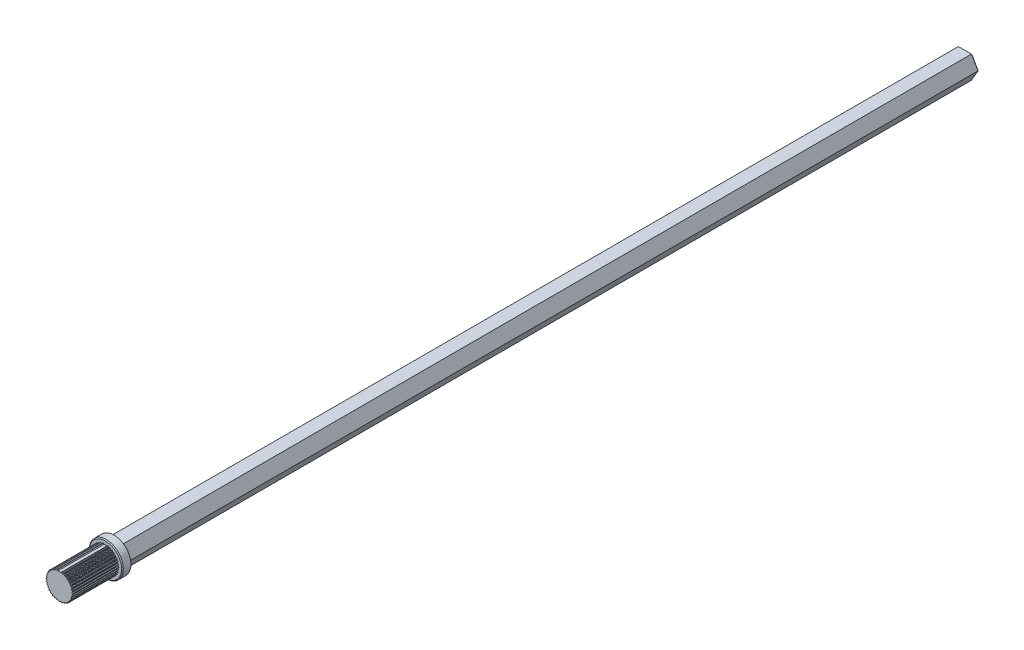
from build123d import *

# Parameters (mm, degrees)
BOSS_EXTRUDE1_DEPTH = 500
SKETCH2_R           = 10
BOSS_EXTRUDE2_DEPTH = 5
BOSS_EXTRUDE3_DEPTH = 27
PAH1_SIZE           = 0.5


with BuildPart() as part:
    # Sketch1 → Boss-Extrude1 (new body)
    with BuildSketch(Plane.XY):
        Polygon((7.696079088, 0), (3.848039544, 6.665), (-3.848039544, 6.665), (-7.696079088, 0), (-3.848039544, -6.665), (3.848039544, -6.665), align=None)
    extrude(amount=BOSS_EXTRUDE1_DEPTH)

    # Sketch2 → Boss-Extrude2 (add)
    with BuildSketch(Plane.XY.offset(500)):
        Circle(SKETCH2_R)
    extrude(amount=BOSS_EXTRUDE2_DEPTH)

    # Sketch3 → Boss-Extrude3 (add)
    with BuildSketch(Plane.XY.offset(505)):
        with BuildLine():
            Line((5.932852577, 5.108414624), (5.40374633, 5.108414624))
            ThreePointArc((5.40374633, 5.108414624), (5.258154352, 5.258154352), (5.108414624, 5.40374633))
            Line((5.108414624, 5.40374633), (5.108414624, 5.932852577))
            ThreePointArc((5.108414624, 5.932852577), (5.061919783, 6.032561087), (4.955652325, 6.061035366))
            Line((4.955652325, 6.061035366), (4.434584391, 5.96915703))
            ThreePointArc((4.434584391, 5.96915703), (4.265202251, 6.091340093), (4.092455625, 6.208718171))
            Line((4.092455625, 6.208718171), (4.000577289, 6.729786106))
            ThreePointArc((4.000577289, 6.729786106), (3.937474608, 6.819906075), (3.827877085, 6.829494615))
            Line((3.827877085, 6.829494615), (3.330679849, 6.648529621))
            ThreePointArc((3.330679849, 6.648529621), (3.142654138, 6.739443548), (2.952149432, 6.825041253))
            Line((2.952149432, 6.825041253), (2.771184438, 7.322238489))
            ThreePointArc((2.771184438, 7.322238489), (2.69339126, 7.400031667), (2.583793737, 7.390443126))
            Line((2.583793737, 7.390443126), (2.125574285, 7.125890003))
            ThreePointArc((2.125574285, 7.125890003), (1.92461807, 7.182772421), (1.722143673, 7.23398891))
            Line((1.722143673, 7.23398891), (1.457590549, 7.692208361))
            ThreePointArc((1.457590549, 7.692208361), (1.367470581, 7.755311042), (1.261203123, 7.726836763))
            Line((1.261203123, 7.726836763), (0.855884222, 7.386733823))
            Line((0.855884222, 7.386733823), (-0.855884222, 7.386733823))
            Line((-0.855884222, 7.386733823), (-1.261203123, 7.726836763))
            ThreePointArc((-1.261203123, 7.726836763), (-1.367470581, 7.755311042), (-1.457590549, 7.692208361))
            Line((-1.457590549, 7.692208361), (-1.722143673, 7.23398891))
            ThreePointArc((-1.722143673, 7.23398891), (-1.92461807, 7.182772421), (-2.125574285, 7.125890003))
            Line((-2.125574285, 7.125890003), (-2.583793737, 7.390443126))
            ThreePointArc((-2.583793737, 7.390443126), (-2.69339126, 7.400031667), (-2.771184438, 7.322238489))
            Line((-2.771184438, 7.322238489), (-2.952149432, 6.825041253))
            ThreePointArc((-2.952149432, 6.825041253), (-3.142654138, 6.739443548), (-3.330679849, 6.648529621))
            Line((-3.330679849, 6.648529621), (-3.827877085, 6.829494615))
            ThreePointArc((-3.827877085, 6.829494615), (-3.937474608, 6.819906075), (-4.000577289, 6.729786106))
            Line((-4.000577289, 6.729786106), (-4.092455625, 6.208718171))
            ThreePointArc((-4.092455625, 6.208718171), (-4.265202251, 6.091340093), (-4.434584391, 5.96915703))
            Line((-4.434584391, 5.96915703), (-4.955652325, 6.061035366))
            ThreePointArc((-4.955652325, 6.061035366), (-5.061919783, 6.032561087), (-5.108414624, 5.932852577))
            Line((-5.108414624, 5.932852577), (-5.108414624, 5.40374633))
            ThreePointArc((-5.108414624, 5.40374633), (-5.258154352, 5.258154352), (-5.40374633, 5.108414624))
            Line((-5.40374633, 5.108414624), (-5.932852577, 5.108414624))
            ThreePointArc((-5.932852577, 5.108414624), (-6.032561087, 5.061919783), (-6.061035366, 4.955652325))
            Line((-6.061035366, 4.955652325), (-5.96915703, 4.434584391))
            ThreePointArc((-5.96915703, 4.434584391), (-6.091340093, 4.265202251), (-6.208718171, 4.092455625))
            Line((-6.208718171, 4.092455625), (-6.729786106, 4.000577289))
            ThreePointArc((-6.729786106, 4.000577289), (-6.819906075, 3.937474608), (-6.829494615, 3.827877085))
            Line((-6.829494615, 3.827877085), (-6.648529621, 3.330679849))
            ThreePointArc((-6.648529621, 3.330679849), (-6.739443548, 3.142654138), (-6.825041253, 2.952149432))
            Line((-6.825041253, 2.952149432), (-7.322238489, 2.771184438))
            ThreePointArc((-7.322238489, 2.771184438), (-7.400031667, 2.69339126), (-7.390443126, 2.583793737))
            Line((-7.390443126, 2.583793737), (-7.125890003, 2.125574285))
            ThreePointArc((-7.125890003, 2.125574285), (-7.182772421, 1.92461807), (-7.23398891, 1.722143673))
            Line((-7.23398891, 1.722143673), (-7.692208361, 1.457590549))
            ThreePointArc((-7.692208361, 1.457590549), (-7.755311042, 1.367470581), (-7.726836763, 1.261203123))
            Line((-7.726836763, 1.261203123), (-7.386733823, 0.855884222))
            ThreePointArc((-7.386733823, 0.855884222), (-7.407856389, 0.648103455), (-7.423135474, 0.439811449))
            Line((-7.423135474, 0.439811449), (-7.828454374, 0.099708509))
            ThreePointArc((-7.828454374, 0.099708509), (-7.874949216, 0), (-7.828454374, -0.099708509))
            Line((-7.828454374, -0.099708509), (-7.423135474, -0.439811449))
            ThreePointArc((-7.423135474, -0.439811449), (-7.407856389, -0.648103455), (-7.386733823, -0.855884222))
            Line((-7.386733823, -0.855884222), (-7.726836763, -1.261203123))
            ThreePointArc((-7.726836763, -1.261203123), (-7.755311042, -1.367470581), (-7.692208361, -1.457590549))
            Line((-7.692208361, -1.457590549), (-7.23398891, -1.722143673))
            ThreePointArc((-7.23398891, -1.722143673), (-7.182772421, -1.92461807), (-7.125890003, -2.125574285))
            Line((-7.125890003, -2.125574285), (-7.390443126, -2.583793737))
            ThreePointArc((-7.390443126, -2.583793737), (-7.400031667, -2.69339126), (-7.322238489, -2.771184438))
            Line((-7.322238489, -2.771184438), (-6.825041253, -2.952149432))
            ThreePointArc((-6.825041253, -2.952149432), (-6.739443548, -3.142654138), (-6.648529621, -3.330679849))
            Line((-6.648529621, -3.330679849), (-6.829494615, -3.827877085))
            ThreePointArc((-6.829494615, -3.827877085), (-6.819906075, -3.937474608), (-6.729786106, -4.000577289))
            Line((-6.729786106, -4.000577289), (-6.208718171, -4.092455625))
            ThreePointArc((-6.208718171, -4.092455625), (-6.091340093, -4.265202251), (-5.96915703, -4.434584391))
            Line((-5.96915703, -4.434584391), (-6.061035366, -4.955652325))
            ThreePointArc((-6.061035366, -4.955652325), (-6.032561087, -5.061919783), (-5.932852577, -5.108414624))
            Line((-5.932852577, -5.108414624), (-5.40374633, -5.108414624))
            ThreePointArc((-5.40374633, -5.108414624), (-5.258154352, -5.258154352), (-5.108414624, -5.40374633))
            Line((-5.108414624, -5.40374633), (-5.108414624, -5.932852577))
            ThreePointArc((-5.108414624, -5.932852577), (-5.061919783, -6.032561087), (-4.955652325, -6.061035366))
            Line((-4.955652325, -6.061035366), (-4.434584391, -5.96915703))
            ThreePointArc((-4.434584391, -5.96915703), (-4.265202251, -6.091340093), (-4.092455625, -6.208718171))
            Line((-4.092455625, -6.208718171), (-4.000577289, -6.729786106))
            ThreePointArc((-4.000577289, -6.729786106), (-3.937474608, -6.819906075), (-3.827877085, -6.829494615))
            Line((-3.827877085, -6.829494615), (-3.330679849, -6.648529621))
            ThreePointArc((-3.330679849, -6.648529621), (-3.142654138, -6.739443548), (-2.952149432, -6.825041253))
            Line((-2.952149432, -6.825041253), (-2.771184438, -7.322238489))
            ThreePointArc((-2.771184438, -7.322238489), (-2.69339126, -7.400031667), (-2.583793737, -7.390443126))
            Line((-2.583793737, -7.390443126), (-2.125574285, -7.125890003))
            ThreePointArc((-2.125574285, -7.125890003), (-1.92461807, -7.182772421), (-1.722143673, -7.23398891))
            Line((-1.722143673, -7.23398891), (-1.457590549, -7.692208361))
            ThreePointArc((-1.457590549, -7.692208361), (-1.367470581, -7.755311042), (-1.261203123, -7.726836763))
            Line((-1.261203123, -7.726836763), (-0.855884222, -7.386733823))
            ThreePointArc((-0.855884222, -7.386733823), (-0.648103455, -7.407856389), (-0.439811449, -7.423135474))
            Line((-0.439811449, -7.423135474), (-0.099708509, -7.828454374))
            ThreePointArc((-0.099708509, -7.828454374), (0, -7.874949216), (0.099708509, -7.828454374))
            Line((0.099708509, -7.828454374), (0.439811449, -7.423135474))
            ThreePointArc((0.439811449, -7.423135474), (0.648103455, -7.407856389), (0.855884222, -7.386733823))
            Line((0.855884222, -7.386733823), (1.261203123, -7.726836763))
            ThreePointArc((1.261203123, -7.726836763), (1.367470581, -7.755311042), (1.457590549, -7.692208361))
            Line((1.457590549, -7.692208361), (1.722143673, -7.23398891))
            ThreePointArc((1.722143673, -7.23398891), (1.92461807, -7.182772421), (2.125574285, -7.125890003))
            Line((2.125574285, -7.125890003), (2.583793737, -7.390443126))
            ThreePointArc((2.583793737, -7.390443126), (2.69339126, -7.400031667), (2.771184438, -7.322238489))
            Line((2.771184438, -7.322238489), (2.952149432, -6.825041253))
            ThreePointArc((2.952149432, -6.825041253), (3.142654138, -6.739443548), (3.330679849, -6.648529621))
            Line((3.330679849, -6.648529621), (3.827877085, -6.829494615))
            ThreePointArc((3.827877085, -6.829494615), (3.937474608, -6.819906075), (4.000577289, -6.729786106))
            Line((4.000577289, -6.729786106), (4.092455625, -6.208718171))
            ThreePointArc((4.092455625, -6.208718171), (4.265202251, -6.091340093), (4.434584391, -5.96915703))
            Line((4.434584391, -5.96915703), (4.955652325, -6.061035366))
            ThreePointArc((4.955652325, -6.061035366), (5.061919783, -6.032561087), (5.108414624, -5.932852577))
            Line((5.108414624, -5.932852577), (5.108414624, -5.40374633))
            ThreePointArc((5.108414624, -5.40374633), (5.258154352, -5.258154352), (5.40374633, -5.108414624))
            Line((5.40374633, -5.108414624), (5.932852577, -5.108414624))
            ThreePointArc((5.932852577, -5.108414624), (6.032561087, -5.061919783), (6.061035366, -4.955652325))
            Line((6.061035366, -4.955652325), (5.96915703, -4.434584391))
            ThreePointArc((5.96915703, -4.434584391), (6.091340093, -4.265202251), (6.208718171, -4.092455625))
            Line((6.208718171, -4.092455625), (6.729786106, -4.000577289))
            ThreePointArc((6.729786106, -4.000577289), (6.819906075, -3.937474608), (6.829494615, -3.827877085))
            Line((6.829494615, -3.827877085), (6.648529621, -3.330679849))
            ThreePointArc((6.648529621, -3.330679849), (6.739443548, -3.142654138), (6.825041253, -2.952149432))
            Line((6.825041253, -2.952149432), (7.322238489, -2.771184438))
            ThreePointArc((7.322238489, -2.771184438), (7.400031667, -2.69339126), (7.390443126, -2.583793737))
            Line((7.390443126, -2.583793737), (7.125890003, -2.125574285))
            ThreePointArc((7.125890003, -2.125574285), (7.182772421, -1.92461807), (7.23398891, -1.722143673))
            Line((7.23398891, -1.722143673), (7.692208361, -1.457590549))
            ThreePointArc((7.692208361, -1.457590549), (7.755311042, -1.367470581), (7.726836763, -1.261203123))
            Line((7.726836763, -1.261203123), (7.386733823, -0.855884222))
            ThreePointArc((7.386733823, -0.855884222), (7.407856389, -0.648103455), (7.423135474, -0.439811449))
            Line((7.423135474, -0.439811449), (7.828454374, -0.099708509))
            ThreePointArc((7.828454374, -0.099708509), (7.874949216, 0), (7.828454374, 0.099708509))
            Line((7.828454374, 0.099708509), (7.423135474, 0.439811449))
            ThreePointArc((7.423135474, 0.439811449), (7.407856389, 0.648103455), (7.386733823, 0.855884222))
            Line((7.386733823, 0.855884222), (7.726836763, 1.261203123))
            ThreePointArc((7.726836763, 1.261203123), (7.755311042, 1.367470581), (7.692208361, 1.457590549))
            Line((7.692208361, 1.457590549), (7.23398891, 1.722143673))
            ThreePointArc((7.23398891, 1.722143673), (7.182772421, 1.92461807), (7.125890003, 2.125574285))
            Line((7.125890003, 2.125574285), (7.390443126, 2.583793737))
            ThreePointArc((7.390443126, 2.583793737), (7.400031667, 2.69339126), (7.322238489, 2.771184438))
            Line((7.322238489, 2.771184438), (6.825041253, 2.952149432))
            ThreePointArc((6.825041253, 2.952149432), (6.739443548, 3.142654138), (6.648529621, 3.330679849))
            Line((6.648529621, 3.330679849), (6.829494615, 3.827877085))
            ThreePointArc((6.829494615, 3.827877085), (6.819906075, 3.937474608), (6.729786106, 4.000577289))
            Line((6.729786106, 4.000577289), (6.208718171, 4.092455625))
            ThreePointArc((6.208718171, 4.092455625), (6.091340093, 4.265202251), (5.96915703, 4.434584391))
            Line((5.96915703, 4.434584391), (6.061035366, 4.955652325))
            ThreePointArc((6.061035366, 4.955652325), (6.032561087, 5.061919783), (5.932852577, 5.108414624))
        make_face()
    extrude(amount=BOSS_EXTRUDE3_DEPTH)

    # Pah1
    pah1_edges = [part.edges().sort_by_distance(p)[0] for p in [
        (-10, 0, 505),
        (0, -6.665, 0),
        (-5.772059316, -3.3325, 0),
        (-5.772059316, 3.3325, 0),
        (0, 6.665, 0),
        (5.772059316, 3.3325, 0),
        (5.772059316, -3.3325, 0),
    ]]
    chamfer(pah1_edges, length=PAH1_SIZE)


solid = part.part
